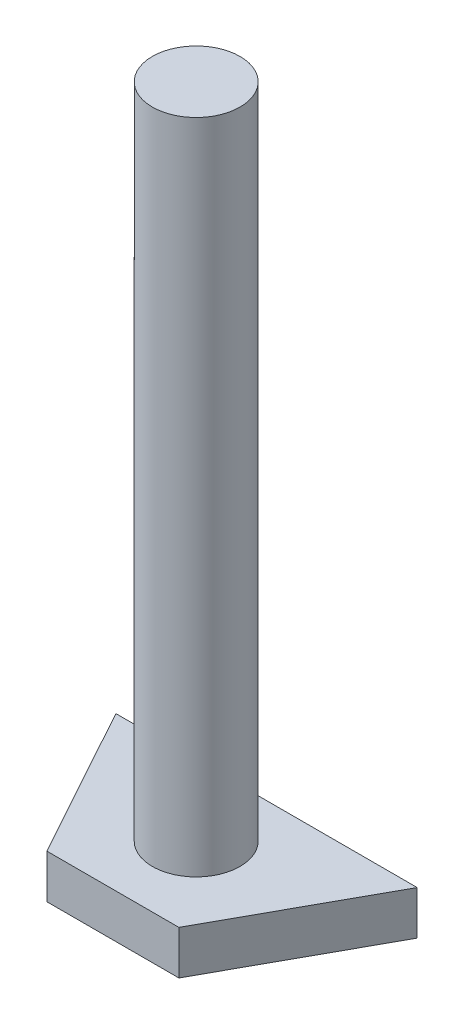
from build123d import *

# Parameters (mm, degrees)
SKETCH1_R           = 2
BOSS_EXTRUDE1_DEPTH = 30
BOSS_EXTRUDE2_DEPTH = 2


with BuildPart() as part:
    # Sketch1 → Boss-Extrude1 (new body)
    with BuildSketch(Plane(origin=(0, 0, 0), x_dir=(1, 0, 0), z_dir=(0, 1, 0))):
        with Locations((76.558114335, 38.393702022)):
            Circle(SKETCH1_R)
    extrude(amount=BOSS_EXTRUDE1_DEPTH)

    # Sketch2 → Boss-Extrude2 (add)
    with BuildSketch(Plane.XZ):
        Polygon((79.569925871, -34.594742746), (73.5463028, -34.594742746), (69.687221965, -41.602416762), (83.429006706, -41.602416762), align=None)
    extrude(amount=BOSS_EXTRUDE2_DEPTH)


solid = part.part
